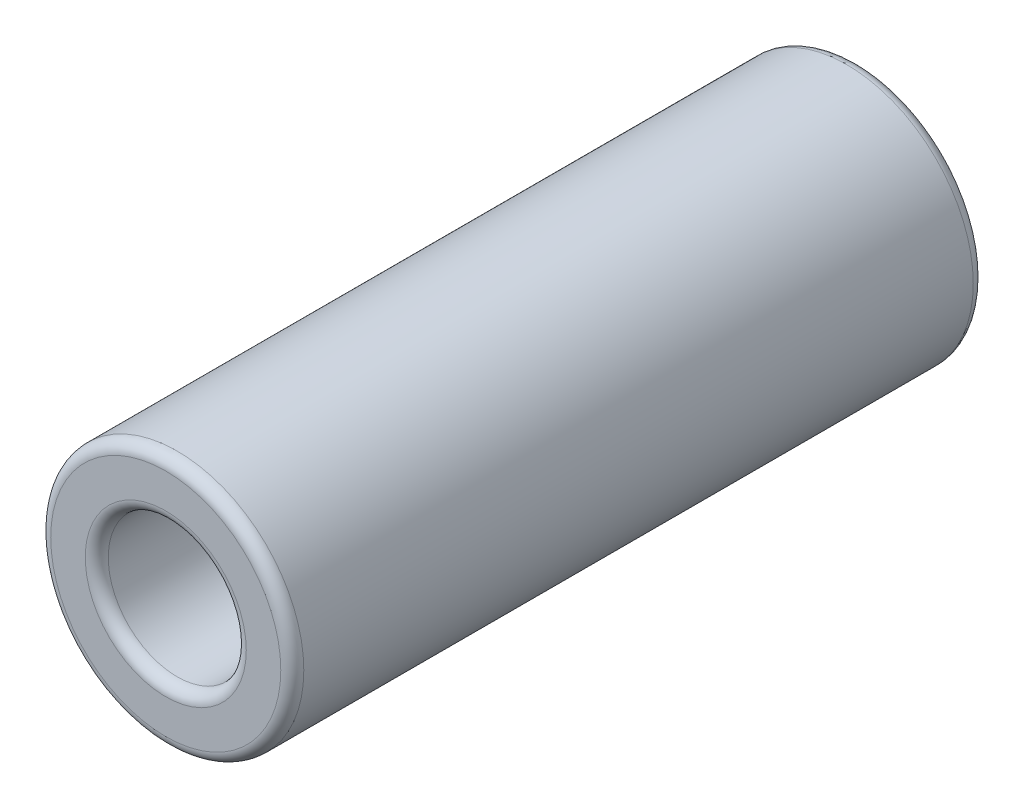
from build123d import *

# Parameters (mm, degrees)
SKETCH1_R           = 5.5
BOSS_EXTRUDE1_DEPTH = 30.1
SKETCH2_R           = 3
CUT_EXTRUDE1_DEPTH  = 31.1
FILLET1_R           = 0.5


with BuildPart() as part:
    # Sketch1 → Boss-Extrude1 (new body)
    with BuildSketch(Plane.XY):
        Circle(SKETCH1_R)
    extrude(amount=BOSS_EXTRUDE1_DEPTH)

    # Sketch2 → Cut-Extrude1 (cut, through all)
    with BuildSketch(Plane.XY.offset(30.1)):
        Circle(SKETCH2_R)
    extrude(amount=-CUT_EXTRUDE1_DEPTH, mode=Mode.SUBTRACT)

    # Fillet1
    fillet1_edges = [part.edges().sort_by_distance(p)[0] for p in [
        (-5.5, 0, 0),
        (-5.5, 0, 30.1),
        (-3, 0, 0),
        (-3, 0, 30.1),
    ]]
    fillet(fillet1_edges, radius=FILLET1_R)


solid = part.part
